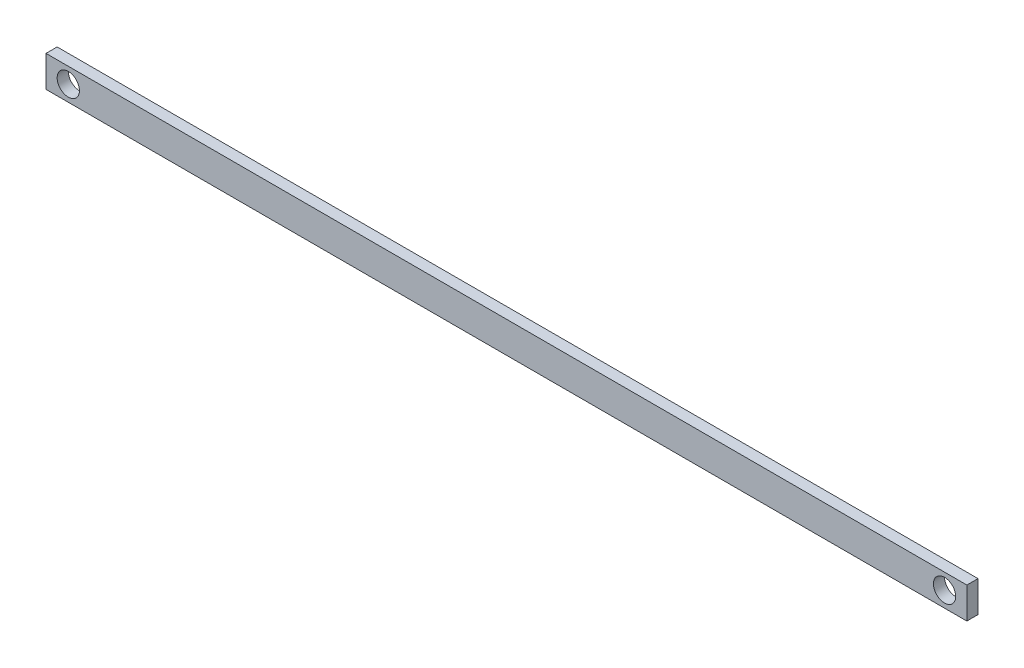
from build123d import *

# Parameters (mm, degrees)
SKETCH1_W           = 3930
SKETCH1_H           = 140
BOSS_EXTRUDE1_DEPTH = 50
SKETCH2_R           = 50
CUT_EXTRUDE1_DEPTH  = 50
SKETCH3_W           = 100
SKETCH3_H           = 140
BOSS_EXTRUDE2_DEPTH = 50
SKETCH4_R           = 50
CUT_EXTRUDE2_DEPTH  = 51


with BuildPart() as part:
    # Sketch1 → Boss-Extrude1 (new body)
    with BuildSketch(Plane.XY):
        with Locations((1965, 70)):
            Rectangle(SKETCH1_W, SKETCH1_H)
    extrude(amount=BOSS_EXTRUDE1_DEPTH)

    # Sketch2 → Cut-Extrude1 (cut)
    with BuildSketch(Plane.XY.offset(50)):
        with Locations((3930, 70)):
            Circle(SKETCH2_R)
        with Locations((0, 70)):
            Circle(SKETCH2_R)
    extrude(amount=-CUT_EXTRUDE1_DEPTH, mode=Mode.SUBTRACT)

    # Sketch3 → Boss-Extrude2 (add, through all)
    with BuildSketch(Plane(origin=(0, 0, 0), x_dir=(-1, 0, 0), z_dir=(0, 0, -1))):
        with Locations((-3980, 70)):
            Rectangle(SKETCH3_W, SKETCH3_H)
        with Locations((50, 70)):
            Rectangle(SKETCH3_W, SKETCH3_H)
    extrude(amount=-BOSS_EXTRUDE2_DEPTH)

    # Sketch4 → Cut-Extrude2 (cut, through all)
    with BuildSketch(Plane(origin=(0, 0, 0), x_dir=(-1, 0, 0), z_dir=(0, 0, -1))):
        with Locations((0, 70)):
            Circle(SKETCH4_R)
        with Locations((-3930, 70)):
            Circle(SKETCH4_R)
    extrude(amount=-CUT_EXTRUDE2_DEPTH, mode=Mode.SUBTRACT)


solid = part.part
